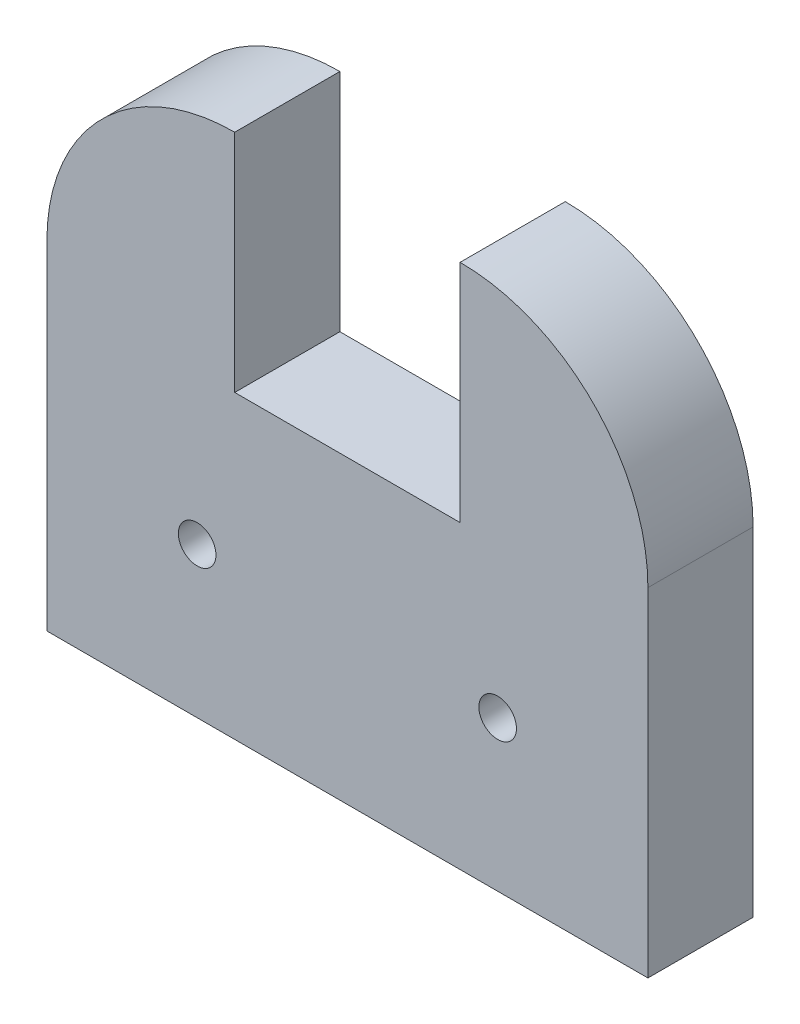
from build123d import *

# Parameters (mm, degrees)
SKETCH1_W           = 101.6
SKETCH1_H           = 88.9
BOSS_EXTRUDE1_DEPTH = 17.78
SKETCH2_R           = 3.175
CUT_EXTRUDE1_DEPTH  = 18.78
FILLET1_R           = 31.75
SKETCH3_W           = 38.1
SKETCH3_H           = 38.1
CUT_EXTRUDE2_DEPTH  = 18.78


with BuildPart() as part:
    # Sketch1 → Boss-Extrude1 (new body)
    with BuildSketch(Plane.XY):
        with Locations((4.927530561, 7.6106367)):
            Rectangle(SKETCH1_W, SKETCH1_H)
    extrude(amount=BOSS_EXTRUDE1_DEPTH)

    # Sketch2 → Cut-Extrude1 (cut, through all)
    with BuildSketch(Plane.XY.offset(17.78)):
        with Locations((-20.472469439, -11.4393633)):
            Circle(SKETCH2_R)
        with Locations((30.327530561, -11.4393633)):
            Circle(SKETCH2_R)
    extrude(amount=-CUT_EXTRUDE1_DEPTH, mode=Mode.SUBTRACT)

    # Fillet1
    fillet1_edges = [part.edges().sort_by_distance(p)[0] for p in [
        (-45.872469439, 52.0606367, 8.89),
        (55.727530561, 52.0606367, 8.89),
    ]]
    fillet(fillet1_edges, radius=FILLET1_R)

    # Sketch3 → Cut-Extrude2 (cut, through all)
    with BuildSketch(Plane.XY.offset(17.78)):
        with Locations((4.927530561, 33.0106367)):
            Rectangle(SKETCH3_W, SKETCH3_H)
    extrude(amount=-CUT_EXTRUDE2_DEPTH, mode=Mode.SUBTRACT)


solid = part.part
